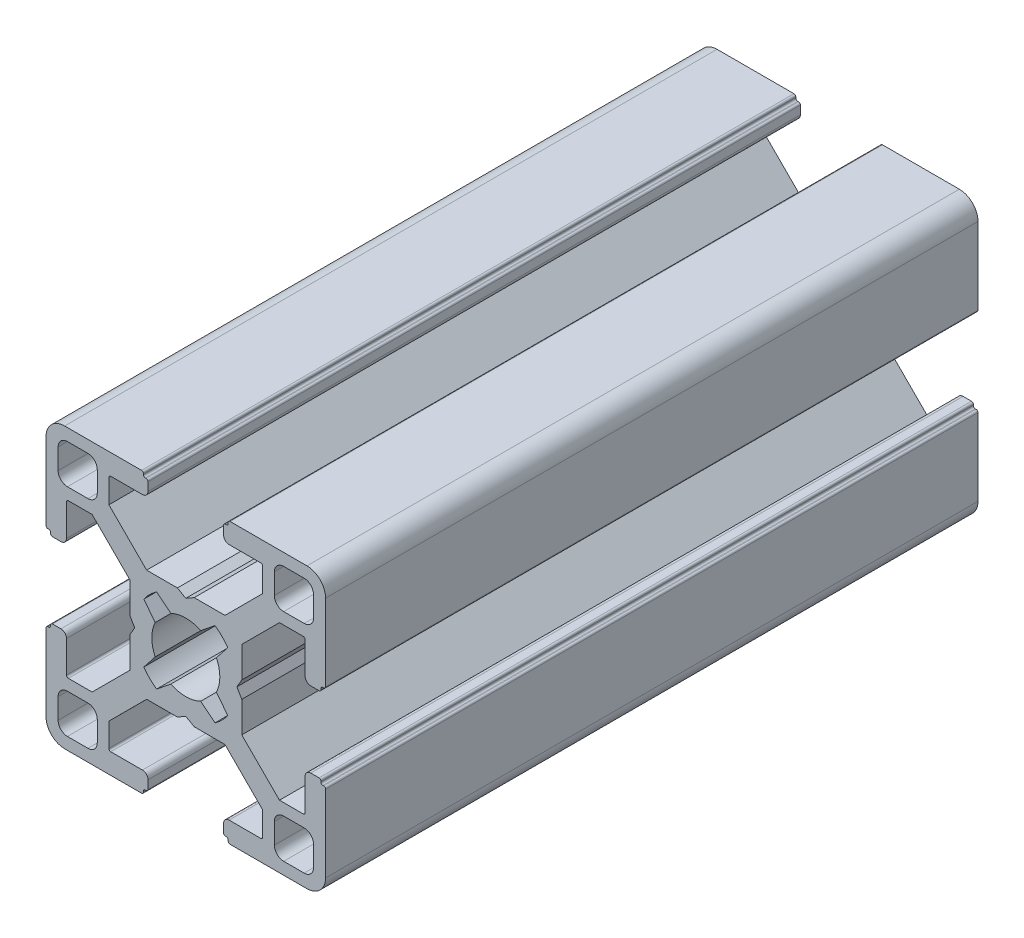
from build123d import *

# Parameters (mm, degrees)
BASE_EXTRUDE_DEPTH = 70


with BuildPart() as part:
    # Sketch1 → Base-Extrude (new body)
    with BuildSketch(Plane.XY):
        with BuildLine():
            Line((6.00446543, 0.899999619), (5.484852164, 0))
            Line((5.484852164, 0), (6.00446543, -0.899999619))
            Line((6.00446543, -0.899999619), (6.00446543, -4.204465866))
            Line((6.00446543, -4.204465866), (10.049999564, -8.25))
            Line((10.049999564, -8.25), (12.59999928, -8.25))
            ThreePointArc((12.59999928, -8.25), (12.741420837, -8.191421273), (12.799999564, -8.049999716))
            Line((12.799999564, -8.049999716), (12.799999564, -4.649999613))
            ThreePointArc((12.799999564, -4.649999613), (12.975735606, -4.225735278), (13.39999994, -4.049999237))
            Line((13.39999994, -4.049999237), (14.300000043, -4.049999237))
            ThreePointArc((14.300000043, -4.049999237), (14.4414216, -4.108577964), (14.500000327, -4.249999521))
            Line((14.500000327, -4.249999521), (14.500000327, -4.349998953))
            ThreePointArc((14.500000327, -4.349998953), (14.558579054, -4.49142051), (14.700000611, -4.549999237))
            Line((14.700000611, -4.549999237), (14.799999716, -4.549999237))
            ThreePointArc((14.799999716, -4.549999237), (14.941421273, -4.608577964), (15, -4.749999521))
            Line((15, -4.749999521), (15, -13.000000346))
            ThreePointArc((15, -13.000000346), (14.414213664, -14.414213664), (13.000000346, -15))
            Line((13.000000346, -15), (4.749999945, -15))
            ThreePointArc((4.749999945, -15), (4.60857832, -14.941421245), (4.549999564, -14.799999619))
            Line((4.549999564, -14.799999619), (4.549999564, -14.69999942))
            ThreePointArc((4.549999564, -14.69999942), (4.49142109, -14.558578474), (4.350000144, -14.5))
            Line((4.350000144, -14.5), (4.250000374, -14.5))
            ThreePointArc((4.250000374, -14.5), (4.108578753, -14.441421247), (4.05, -14.299999626))
            Line((4.05, -14.299999626), (4.05, -13.399999434))
            ThreePointArc((4.05, -13.399999434), (4.225735989, -12.975735226), (4.650000197, -12.799999237))
            Line((4.650000197, -12.799999237), (8.049999924, -12.799999237))
            ThreePointArc((8.049999924, -12.799999237), (8.191421565, -12.741420475), (8.250000327, -12.599998834))
            Line((8.250000327, -12.599998834), (8.250000327, -10.049999237))
            Line((8.250000327, -10.049999237), (4.204466193, -6))
            Line((4.204466193, -6), (0.899999946, -6))
            Line((0.899999946, -6), (0, -5.484851837))
            Line((0, -5.484851837), (-0.899999946, -6))
            Line((-0.899999946, -6), (-4.204466193, -6))
            Line((-4.204466193, -6), (-8.250000327, -10.049999237))
            Line((-8.250000327, -10.049999237), (-8.250000327, -12.599998834))
            ThreePointArc((-8.250000327, -12.599998834), (-8.191421565, -12.741420475), (-8.049999924, -12.799999237))
            Line((-8.049999924, -12.799999237), (-4.650000197, -12.799999237))
            ThreePointArc((-4.650000197, -12.799999237), (-4.225735989, -12.975735226), (-4.05, -13.399999434))
            Line((-4.05, -13.399999434), (-4.05, -14.299999626))
            ThreePointArc((-4.05, -14.299999626), (-4.108578753, -14.441421247), (-4.250000374, -14.5))
            Line((-4.250000374, -14.5), (-4.350000144, -14.5))
            ThreePointArc((-4.350000144, -14.5), (-4.49142109, -14.558578474), (-4.549999564, -14.69999942))
            Line((-4.549999564, -14.69999942), (-4.549999564, -14.799999619))
            ThreePointArc((-4.549999564, -14.799999619), (-4.60857832, -14.941421245), (-4.749999945, -15))
            Line((-4.749999945, -15), (-13.000000346, -15))
            ThreePointArc((-13.000000346, -15), (-14.414213664, -14.414213664), (-15, -13.000000346))
            Line((-15, -13.000000346), (-15, -4.749999521))
            ThreePointArc((-15, -4.749999521), (-14.941421273, -4.608577964), (-14.799999716, -4.549999237))
            Line((-14.799999716, -4.549999237), (-14.700000611, -4.549999237))
            ThreePointArc((-14.700000611, -4.549999237), (-14.558579054, -4.49142051), (-14.500000327, -4.349998953))
            Line((-14.500000327, -4.349998953), (-14.500000327, -4.249999521))
            ThreePointArc((-14.500000327, -4.249999521), (-14.4414216, -4.108577964), (-14.300000043, -4.049999237))
            Line((-14.300000043, -4.049999237), (-13.39999994, -4.049999237))
            ThreePointArc((-13.39999994, -4.049999237), (-12.975735606, -4.225735278), (-12.799999564, -4.649999613))
            Line((-12.799999564, -4.649999613), (-12.799999564, -8.049999716))
            ThreePointArc((-12.799999564, -8.049999716), (-12.741420837, -8.191421273), (-12.59999928, -8.25))
            Line((-12.59999928, -8.25), (-10.049999564, -8.25))
            Line((-10.049999564, -8.25), (-6.00446543, -4.204465866))
            Line((-6.00446543, -4.204465866), (-6.00446543, -0.899999619))
            Line((-6.00446543, -0.899999619), (-5.484852164, 0))
            Line((-5.484852164, 0), (-6.00446543, 0.899999619))
            Line((-6.00446543, 0.899999619), (-6.00446543, 4.204465866))
            Line((-6.00446543, 4.204465866), (-10.049999564, 8.25))
            Line((-10.049999564, 8.25), (-12.59999928, 8.25))
            ThreePointArc((-12.59999928, 8.25), (-12.741420837, 8.191421273), (-12.799999564, 8.049999716))
            Line((-12.799999564, 8.049999716), (-12.799999564, 4.649999613))
            ThreePointArc((-12.799999564, 4.649999613), (-12.975735606, 4.225735278), (-13.39999994, 4.049999237))
            Line((-13.39999994, 4.049999237), (-14.300000043, 4.049999237))
            ThreePointArc((-14.300000043, 4.049999237), (-14.4414216, 4.108577964), (-14.500000327, 4.249999521))
            Line((-14.500000327, 4.249999521), (-14.500000327, 4.349998953))
            ThreePointArc((-14.500000327, 4.349998953), (-14.558579054, 4.49142051), (-14.700000611, 4.549999237))
            Line((-14.700000611, 4.549999237), (-14.799999716, 4.549999237))
            ThreePointArc((-14.799999716, 4.549999237), (-14.941421273, 4.608577964), (-15, 4.749999521))
            Line((-15, 4.749999521), (-15, 13.000000346))
            ThreePointArc((-15, 13.000000346), (-14.414213664, 14.414213664), (-13.000000346, 15))
            Line((-13.000000346, 15), (-4.749999945, 15))
            ThreePointArc((-4.749999945, 15), (-4.60857832, 14.941421245), (-4.549999564, 14.799999619))
            Line((-4.549999564, 14.799999619), (-4.549999564, 14.69999942))
            ThreePointArc((-4.549999564, 14.69999942), (-4.49142109, 14.558578474), (-4.350000144, 14.5))
            Line((-4.350000144, 14.5), (-4.250000374, 14.5))
            ThreePointArc((-4.250000374, 14.5), (-4.108578753, 14.441421247), (-4.05, 14.299999626))
            Line((-4.05, 14.299999626), (-4.05, 13.399999434))
            ThreePointArc((-4.05, 13.399999434), (-4.225735989, 12.975735226), (-4.650000197, 12.799999237))
            Line((-4.650000197, 12.799999237), (-8.049999924, 12.799999237))
            ThreePointArc((-8.049999924, 12.799999237), (-8.191421565, 12.741420475), (-8.250000327, 12.599998834))
            Line((-8.250000327, 12.599998834), (-8.250000327, 10.049999237))
            Line((-8.250000327, 10.049999237), (-4.204466193, 6))
            Line((-4.204466193, 6), (-0.899999946, 6))
            Line((-0.899999946, 6), (0, 5.484851837))
            Line((0, 5.484851837), (0.899999946, 6))
            Line((0.899999946, 6), (4.204466193, 6))
            Line((4.204466193, 6), (8.250000327, 10.049999237))
            Line((8.250000327, 10.049999237), (8.250000327, 12.599998834))
            ThreePointArc((8.250000327, 12.599998834), (8.191421565, 12.741420475), (8.049999924, 12.799999237))
            Line((8.049999924, 12.799999237), (4.650000197, 12.799999237))
            ThreePointArc((4.650000197, 12.799999237), (4.225735989, 12.975735226), (4.05, 13.399999434))
            Line((4.05, 13.399999434), (4.05, 14.299999626))
            ThreePointArc((4.05, 14.299999626), (4.108578753, 14.441421247), (4.250000374, 14.5))
            Line((4.250000374, 14.5), (4.350000144, 14.5))
            ThreePointArc((4.350000144, 14.5), (4.49142109, 14.558578474), (4.549999564, 14.69999942))
            Line((4.549999564, 14.69999942), (4.549999564, 14.799999619))
            ThreePointArc((4.549999564, 14.799999619), (4.60857832, 14.941421245), (4.749999945, 15))
            Line((4.749999945, 15), (13.000000346, 15))
            ThreePointArc((13.000000346, 15), (14.414213664, 14.414213664), (15, 13.000000346))
            Line((15, 13.000000346), (15, 4.749999521))
            ThreePointArc((15, 4.749999521), (14.941421273, 4.608577964), (14.799999716, 4.549999237))
            Line((14.799999716, 4.549999237), (14.700000611, 4.549999237))
            ThreePointArc((14.700000611, 4.549999237), (14.558579054, 4.49142051), (14.500000327, 4.349998953))
            Line((14.500000327, 4.349998953), (14.500000327, 4.249999521))
            ThreePointArc((14.500000327, 4.249999521), (14.4414216, 4.108577964), (14.300000043, 4.049999237))
            Line((14.300000043, 4.049999237), (13.39999994, 4.049999237))
            ThreePointArc((13.39999994, 4.049999237), (12.975735606, 4.225735278), (12.799999564, 4.649999613))
            Line((12.799999564, 4.649999613), (12.799999564, 8.049999716))
            ThreePointArc((12.799999564, 8.049999716), (12.741420837, 8.191421273), (12.59999928, 8.25))
            Line((12.59999928, 8.25), (10.049999564, 8.25))
            Line((10.049999564, 8.25), (6.00446543, 4.204465866))
            Line((6.00446543, 4.204465866), (6.00446543, 0.899999619))
        make_face()
        with BuildLine():
            Line((13.70000109, 12.700000408), (13.70000109, 10.499999626))
            ThreePointArc((13.70000109, 10.499999626), (13.407107874, 9.792892851), (12.7000011, 9.499999635))
            Line((12.7000011, 9.499999635), (10.500000318, 9.499999635))
            ThreePointArc((10.500000318, 9.499999635), (9.792893543, 9.792892851), (9.500000327, 10.499999626))
            Line((9.500000327, 10.499999626), (9.500000327, 12.700000408))
            ThreePointArc((9.500000327, 12.700000408), (9.792893543, 13.407107182), (10.500000318, 13.700000398))
            Line((10.500000318, 13.700000398), (12.7000011, 13.700000398))
            ThreePointArc((12.7000011, 13.700000398), (13.407107874, 13.407107182), (13.70000109, 12.700000408))
        make_face(mode=Mode.SUBTRACT)
        with BuildLine():
            Line((3.135929412, 4.518400903), (1.600129524, 3.280561767))
            ThreePointArc((1.600129524, 3.280561767), (0, 3.65), (-1.600129524, 3.280561767))
            Line((-1.600129524, 3.280561767), (-3.135929412, 4.518400903))
            ThreePointArc((-3.135929412, 4.518400903), (-3.881002259, 3.897155561), (-4.505336892, 3.154669473))
            Line((-4.505336892, 3.154669473), (-3.280561732, 1.600129597))
            ThreePointArc((-3.280561732, 1.600129597), (-3.65, 0), (-3.280561732, -1.600129597))
            Line((-3.280561732, -1.600129597), (-4.505336892, -3.154669473))
            ThreePointArc((-4.505336892, -3.154669473), (-3.881002259, -3.897155561), (-3.135929412, -4.518400903))
            Line((-3.135929412, -4.518400903), (-1.600129524, -3.280561767))
            ThreePointArc((-1.600129524, -3.280561767), (0, -3.65), (1.600129524, -3.280561767))
            Line((1.600129524, -3.280561767), (3.135929412, -4.518400903))
            ThreePointArc((3.135929412, -4.518400903), (3.881002259, -3.897155561), (4.505336892, -3.154669473))
            Line((4.505336892, -3.154669473), (3.280561732, -1.600129597))
            ThreePointArc((3.280561732, -1.600129597), (3.65, 0), (3.280561732, 1.600129597))
            Line((3.280561732, 1.600129597), (4.505336892, 3.154669473))
            ThreePointArc((4.505336892, 3.154669473), (3.881002259, 3.897155561), (3.135929412, 4.518400903))
        make_face(mode=Mode.SUBTRACT)
        with BuildLine():
            Line((-13.70000109, -12.700000408), (-13.70000109, -10.499999626))
            ThreePointArc((-13.70000109, -10.499999626), (-13.407107874, -9.792892851), (-12.7000011, -9.499999635))
            Line((-12.7000011, -9.499999635), (-10.500000318, -9.499999635))
            ThreePointArc((-10.500000318, -9.499999635), (-9.792893543, -9.792892851), (-9.500000327, -10.499999626))
            Line((-9.500000327, -10.499999626), (-9.500000327, -12.700000408))
            ThreePointArc((-9.500000327, -12.700000408), (-9.792893543, -13.407107182), (-10.500000318, -13.700000398))
            Line((-10.500000318, -13.700000398), (-12.7000011, -13.700000398))
            ThreePointArc((-12.7000011, -13.700000398), (-13.407107874, -13.407107182), (-13.70000109, -12.700000408))
        make_face(mode=Mode.SUBTRACT)
        with BuildLine():
            Line((10.500000318, -13.700000398), (12.7000011, -13.700000398))
            ThreePointArc((12.7000011, -13.700000398), (13.407107874, -13.407107182), (13.70000109, -12.700000408))
            Line((13.70000109, -12.700000408), (13.70000109, -10.499999626))
            ThreePointArc((13.70000109, -10.499999626), (13.407107874, -9.792892851), (12.7000011, -9.499999635))
            Line((12.7000011, -9.499999635), (10.500000318, -9.499999635))
            ThreePointArc((10.500000318, -9.499999635), (9.792893543, -9.792892851), (9.500000327, -10.499999626))
            Line((9.500000327, -10.499999626), (9.500000327, -12.700000408))
            ThreePointArc((9.500000327, -12.700000408), (9.792893543, -13.407107182), (10.500000318, -13.700000398))
        make_face(mode=Mode.SUBTRACT)
        with BuildLine():
            Line((-10.500000318, 13.700000398), (-12.7000011, 13.700000398))
            ThreePointArc((-12.7000011, 13.700000398), (-13.407107874, 13.407107182), (-13.70000109, 12.700000408))
            Line((-13.70000109, 12.700000408), (-13.70000109, 10.499999626))
            ThreePointArc((-13.70000109, 10.499999626), (-13.407107874, 9.792892851), (-12.7000011, 9.499999635))
            Line((-12.7000011, 9.499999635), (-10.500000318, 9.499999635))
            ThreePointArc((-10.500000318, 9.499999635), (-9.792893543, 9.792892851), (-9.500000327, 10.499999626))
            Line((-9.500000327, 10.499999626), (-9.500000327, 12.700000408))
            ThreePointArc((-9.500000327, 12.700000408), (-9.792893543, 13.407107182), (-10.500000318, 13.700000398))
        make_face(mode=Mode.SUBTRACT)
    extrude(amount=-BASE_EXTRUDE_DEPTH)


solid = part.part
